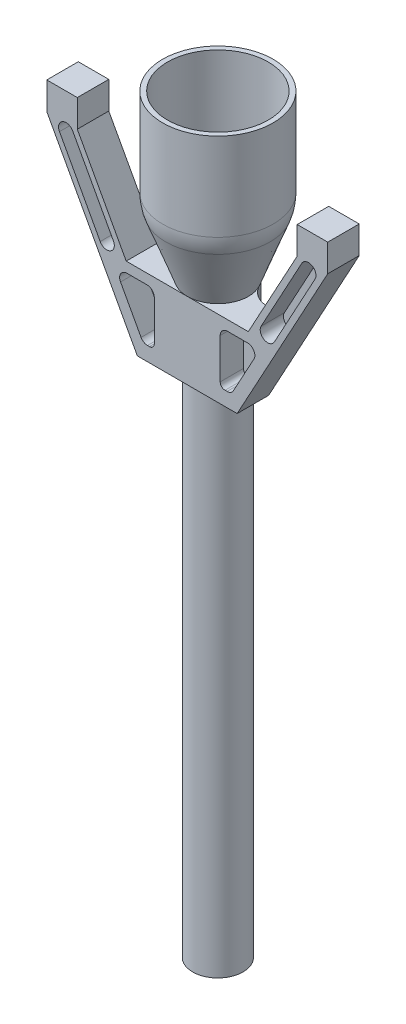
from build123d import *

# Parameters (mm, degrees)
SKETCH1_R               = 5.2
SKETCH1_R_2             = 4.65
BOSS_EXTRUDE1_DEPTH     = 121.35
SKETCH2_R               = 6.32
SKETCH2_R_2             = 4.65
BOSS_EXTRUDE2_DEPTH     = 15.8
SKETCH4_R               = 11.4
SKETCH4_R_2             = 10.4
BOSS_EXTRUDE3_DEPTH     = 19.9
BOSS_EXTRUDE4_DEPTH     = 6.5
CUT_EXTRUDE1_DEPTH      = 4.8
FILLET2_R               = 10
SKETCH8_R               = 4.65
CUT_EXTRUDE2_DEPTH      = 159.003069696
CUT_EXTRUDE2_DEPTH_BACK = 159.003069696
FILLET3_R               = 5
FILLET4_R               = 5


with BuildPart() as part:
    # Sketch1 → Boss-Extrude1 (new body)
    with BuildSketch(Plane(origin=(0, 0, 0), x_dir=(1, 0, 0), z_dir=(0, 1, 0))):
        with Locations(Location((0, 0, 0), (0, 0, 270))):
            Circle(SKETCH1_R)
        with Locations(Location((0, 0, 0), (0, 0, 270))):
            Circle(SKETCH1_R_2, mode=Mode.SUBTRACT)
    extrude(amount=BOSS_EXTRUDE1_DEPTH)

    # Sketch2 → Boss-Extrude2 (add)
    with BuildSketch(Plane(origin=(0, 121.35, 0), x_dir=(1, 0, 0), z_dir=(0, 1, 0))):
        with Locations(Location((0, 0, 0), (0, 0, 270))):
            Circle(SKETCH2_R)
        with Locations(Location((0, 0, 0), (0, 0, 270))):
            Circle(SKETCH2_R_2, mode=Mode.SUBTRACT)
    extrude(amount=-BOSS_EXTRUDE2_DEPTH)

    # Sketch3 → Revolve1 (revolve)
    with BuildSketch(Plane.XY, mode=Mode.PRIVATE) as revolve1_sk:
        Polygon((-6.32, 121.35), (-11.4, 135), (-10.4, 135), (-4.65, 121.35), align=None)
    revolve(revolve1_sk.sketch.rotate(Axis((0, 121.35, 0), (0, -1, 0)), 270), axis=Axis((0, 121.35, 0), (0, -1, 0)))

    # Sketch4 → Boss-Extrude3 (add)
    with BuildSketch(Plane(origin=(0, 135, 0), x_dir=(1, 0, 0), z_dir=(0, 1, 0))):
        with Locations(Location((0, 0, 0), (0, 0, 90))):
            Circle(SKETCH4_R)
        with Locations(Location((0, 0, 0), (0, 0, 90))):
            Circle(SKETCH4_R_2, mode=Mode.SUBTRACT)
    extrude(amount=BOSS_EXTRUDE3_DEPTH)

    # Fillet2
    fillet2_edges = [part.edges().sort_by_distance(p)[0] for p in [
        (-11.4, 135, 0),
    ]]
    fillet(fillet2_edges, radius=FILLET2_R)


with BuildPart() as body_2:
    # Sketch6 → Boss-Extrude4 (new body)
    with BuildSketch(Plane.XY.offset(6.32)):
        Polygon((-10.3, 105.55), (10.3, 105.55), (29, 139.89), (29, 145.55), (22.7, 145.55), (22.7, 139.89), (12.603960396, 121.35), (-12.603960396, 121.35), (-22.7, 139.89), (-22.7, 145.55), (-29, 145.55), (-29, 139.89), align=None)
    extrude(amount=-BOSS_EXTRUDE4_DEPTH)

    # Sketch7 → Cut-Extrude1 (cut)
    with BuildSketch(Plane.XY.offset(6.32)):
        with BuildLine():
            Line((8.3, 119.257622479), (12.456070352, 119.257622479))
            ThreePointArc((12.456070352, 119.257622479), (13.745534607, 118.523965702), (13.773633276, 117.04066506))
            Line((13.773633276, 117.04066506), (9.534103268, 109.249619999))
            ThreePointArc((9.534103268, 109.249619999), (8.982883567, 108.677113163), (8.216540343, 108.466577418))
            Line((8.216540343, 108.466577418), (7.8, 108.466577418))
            ThreePointArc((7.8, 108.466577418), (7.092893219, 108.759470637), (6.8, 109.466577418))
            Line((6.8, 109.466577418), (6.8, 117.757622479))
            ThreePointArc((6.8, 117.757622479), (7.239339828, 118.81828265), (8.3, 119.257622479))
        make_face()
        with BuildLine():
            Line((-15.248616144, 123.653554953), (-23.653367428, 139.099086851))
            ThreePointArc((-23.653367428, 139.099086851), (-25.757025654, 139.720102373), (-26.378041176, 137.616444147))
            Line((-26.378041176, 137.616444147), (-17.973289892, 122.170912249))
            ThreePointArc((-17.973289892, 122.170912249), (-15.869631666, 121.549896727), (-15.248616144, 123.653554953))
        make_face()
        with BuildLine():
            Line((15.248616144, 123.653554953), (23.653367428, 139.099086851))
            ThreePointArc((23.653367428, 139.099086851), (25.757025654, 139.720102373), (26.378041176, 137.616444147))
            Line((26.378041176, 137.616444147), (17.973289892, 122.170912249))
            ThreePointArc((17.973289892, 122.170912249), (15.869631666, 121.549896727), (15.248616144, 123.653554953))
        make_face()
        with BuildLine():
            Line((-8.216540343, 108.466577418), (-7.8, 108.466577418))
            ThreePointArc((-7.8, 108.466577418), (-7.092893219, 108.759470637), (-6.8, 109.466577418))
            Line((-6.8, 109.466577418), (-6.8, 117.757622479))
            ThreePointArc((-6.8, 117.757622479), (-7.239339828, 118.81828265), (-8.3, 119.257622479))
            Line((-8.3, 119.257622479), (-12.456070352, 119.257622479))
            ThreePointArc((-12.456070352, 119.257622479), (-13.745534607, 118.523965702), (-13.773633276, 117.04066506))
            Line((-13.773633276, 117.04066506), (-9.534103268, 109.249619999))
            ThreePointArc((-9.534103268, 109.249619999), (-8.982883567, 108.677113163), (-8.216540343, 108.466577418))
        make_face()
    extrude(amount=-CUT_EXTRUDE1_DEPTH, mode=Mode.SUBTRACT)

    # Sketch8 → Cut-Extrude2 (cut, two sides)
    with BuildSketch(Plane(origin=(0, 0, 0), x_dir=(1, 0, 0), z_dir=(0, 1, 0))) as cut_extrude2_sk:
        with Locations(Location((0, 0, 0), (0, 0, 270))):
            Circle(SKETCH8_R)
    extrude(amount=CUT_EXTRUDE2_DEPTH, mode=Mode.SUBTRACT)
    extrude(cut_extrude2_sk.sketch, amount=-CUT_EXTRUDE2_DEPTH_BACK, mode=Mode.SUBTRACT)

    # Combine1: union part
    add(part.part)

    # Fillet3
    fillet3_edges = [body_2.edges().sort_by_distance(p)[0] for p in [
        (-6.317436189, 113.45, -0.18),
    ]]
    fillet(fillet3_edges, radius=FILLET3_R)

    # Fillet4
    fillet4_edges = [body_2.edges().sort_by_distance(p)[0] for p in [
        (6.317436189, 113.45, -0.18),
    ]]
    fillet(fillet4_edges, radius=FILLET4_R)


solid = body_2.part
